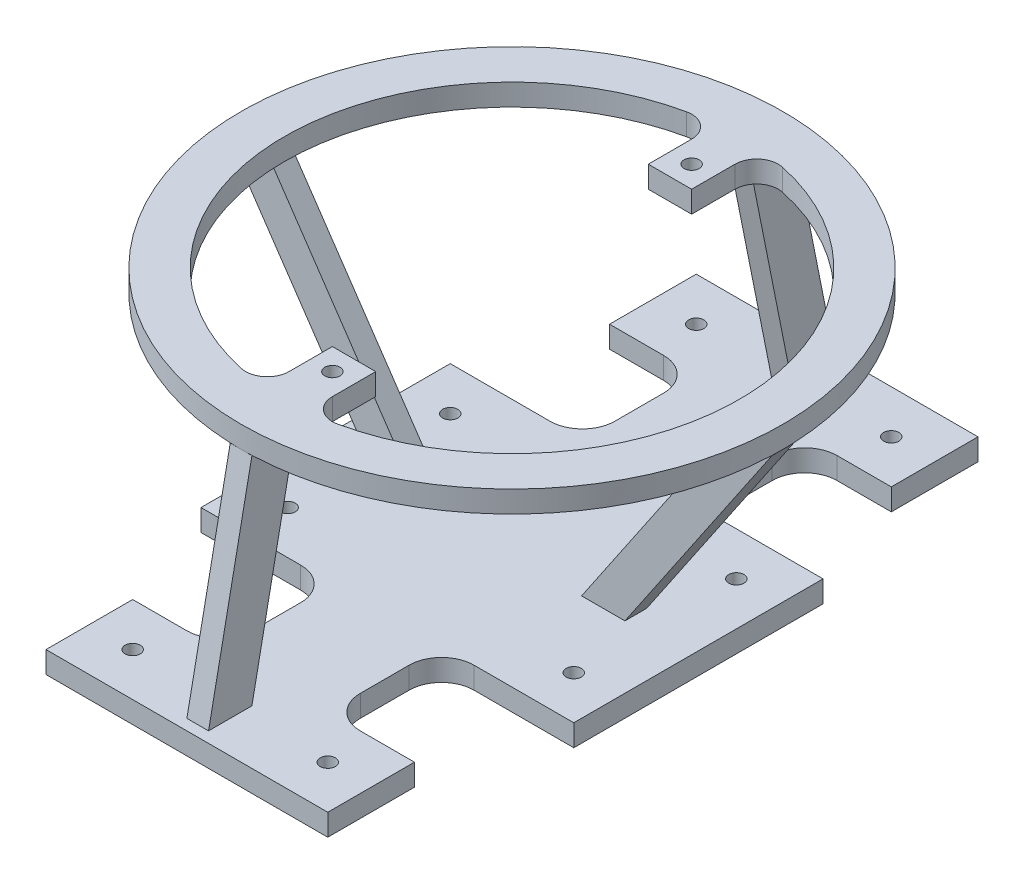
from build123d import *

# Parameters (mm, degrees)
AUFSATZ_LINEAR_AUSTRAGEN1_DEPTH    = 10
SKIZZE6_R                          = 125
AUFSATZ_LINEAR_AUSTRAGEN2_DEPTH    = 10
AUFSATZ_LINEAR_AUSTRAGEN3_DEPTH    = 5
SKIZZE8_W                          = 50
SKIZZE8_H                          = 20
SCHNITT_LINEAR_AUSTRAGEN1_DEPTH    = 10
AUFSATZ_LINEAR_AUSTRAGEN4_DEPTH    = 10
SKIZZE14_W                         = 24
SKIZZE14_H                         = 115
SCHNITT_LINEAR_AUSTRAGEN2_DEPTH    = 10
SKIZZE15_W                         = 24
SKIZZE15_H                         = 115
SCHNITT_LINEAR_AUSTRAGEN3_DEPTH    = 10
AUFSATZ_LINEAR_AUSTRAGEN8_DEPTH    = 5
KERNLOCH_F_R_M8X1_0_GEWINDE2_D     = 7
KERNLOCH_F_R_M8X1_0_GEWINDE2_DEPTH = 20
KERNLOCH_F_R_M8X1_0_GEWINDE2_TIP   = 2.103012167
KERNLOCH_F_R_M8X1_0_GEWINDE3_D     = 7
KERNLOCH_F_R_M8X1_0_GEWINDE3_DEPTH = 20
KERNLOCH_F_R_M8X1_0_GEWINDE3_TIP   = 2.103012167


with BuildPart() as part:
    # Skizze1 → Aufsatz-Linear austragen1 (new body)
    with BuildSketch(Plane(origin=(0, 0, 0), x_dir=(1, 0, 0), z_dir=(0, 1, 0))):
        with BuildLine():
            Line((75.838298065, 35.851170731), (145.838298065, 35.851170731))
            Line((145.838298065, 35.851170731), (145.838298065, -79.148829269))
            Line((145.838298065, -79.148829269), (75.838298065, -79.148829269))
            ThreePointArc((75.838298065, -79.148829269), (65.231696347, -83.542227551), (60.838298065, -94.148829269))
            Line((60.838298065, -94.148829269), (60.838298065, -191.648829269))
            Line((60.838298065, -191.648829269), (10.838298065, -191.648829269))
            Line((10.838298065, -191.648829269), (10.838298065, -94.148829269))
            ThreePointArc((10.838298065, -94.148829269), (6.444899783, -83.542227551), (-4.161701935, -79.148829269))
            Line((-4.161701935, -79.148829269), (-74.161701935, -79.148829269))
            Line((-74.161701935, -79.148829269), (-74.161701935, 35.851170731))
            Line((-74.161701935, 35.851170731), (-4.161701935, 35.851170731))
            ThreePointArc((-4.161701935, 35.851170731), (6.444899783, 40.244569014), (10.838298065, 50.851170731))
            Line((10.838298065, 50.851170731), (10.838298065, 148.351170731))
            Line((10.838298065, 148.351170731), (60.838298065, 148.351170731))
            Line((60.838298065, 148.351170731), (60.838298065, 50.851170731))
            ThreePointArc((60.838298065, 50.851170731), (65.231696347, 40.244569014), (75.838298065, 35.851170731))
        make_face()
    extrude(amount=AUFSATZ_LINEAR_AUSTRAGEN1_DEPTH)



with BuildPart() as body_2:
    # Skizze6 → Aufsatz-Linear austragen2 (new body)
    with BuildSketch(Plane(origin=(0, 120, 0), x_dir=(1, 0, 0), z_dir=(0, 1, 0))):
        with Locations(Location((35.838298065, -21.648829269, 0), (0, 0, 270))):  # turned: the seam where the file's is
            Circle(SKIZZE6_R)
        with BuildLine():
            Line((25.838298065, 71.222048837), (25.838298065, 51.222048837))
            Line((25.838298065, 51.222048837), (45.838298065, 51.222048837))
            Line((45.838298065, 51.222048837), (45.838298065, 71.222048837))
            ThreePointArc((45.838298065, 71.222048837), (49.55548944, 79.001914889), (57.943561223, 80.997930742))
            ThreePointArc((57.943561223, 80.997930742), (140.838298065, -21.648829269), (57.943561223, -124.295589279))
            ThreePointArc((57.943561223, -124.295589279), (49.55548944, -122.299573426), (45.838298065, -114.519707374))
            Line((45.838298065, -114.519707374), (45.838298065, -94.519707374))
            Line((45.838298065, -94.519707374), (25.838298065, -94.519707374))
            Line((25.838298065, -94.519707374), (25.838298065, -114.519707374))
            ThreePointArc((25.838298065, -114.519707374), (22.121106689, -122.299573426), (13.733034907, -124.295589279))
            ThreePointArc((13.733034907, -124.295589279), (-69.161701935, -21.648829269), (13.733034907, 80.997930742))
            ThreePointArc((13.733034907, 80.997930742), (22.121106689, 79.001914889), (25.838298065, 71.222048837))
        make_face(mode=Mode.SUBTRACT)
    extrude(amount=-AUFSATZ_LINEAR_AUSTRAGEN2_DEPTH)


with BuildPart() as part_1:
    add(part.part)

    add(body_2.part)  # Aufsatz-Linear austragen3 merges body 2
    # Skizze7 → Aufsatz-Linear austragen3 (add, symmetric)
    with BuildSketch(Plane(origin=(35.838298065, 0, 0), x_dir=(0, 0, -1), z_dir=(1, 0, 0))):
        Polygon((-146.648829269, 110), (-126.648829269, 110), (-146.648829269, 10), (-166.648829269, 10), align=None)
    aufsatz_linear_austragen3 = extrude(amount=AUFSATZ_LINEAR_AUSTRAGEN3_DEPTH, both=True)

    # Spiegeln1: Aufsatz-Linear austragen3 across plane
    add(aufsatz_linear_austragen3.mirror(Plane.XY.offset(21.648829269)))

    # Skizze8 → Schnitt-Linear austragen1 (cut)
    with BuildSketch(Plane(origin=(0, 10, 0), x_dir=(1, 0, 0), z_dir=(0, 1, 0))):
        with Locations((35.838298065, 138.351170731)):
            Rectangle(SKIZZE8_W, SKIZZE8_H)
        with Locations((35.838298065, -181.648829269)):
            Rectangle(SKIZZE8_W, SKIZZE8_H)
    extrude(amount=-SCHNITT_LINEAR_AUSTRAGEN1_DEPTH, mode=Mode.SUBTRACT)

    # Skizze9 → Aufsatz-Linear austragen4 (add)
    with BuildSketch(Plane(origin=(0, 10, 0), x_dir=(1, 0, 0), z_dir=(0, 1, 0))):
        with BuildLine():
            Line((60.838298065, -131.648829269), (60.838298065, -171.648829269))
            Line((60.838298065, -171.648829269), (100.838298065, -171.648829269))
            Line((100.838298065, -171.648829269), (100.838298065, -131.648829269))
            Line((100.838298065, -131.648829269), (75.838298065, -131.648829269))
            ThreePointArc((75.838298065, -131.648829269), (65.231696347, -127.255430986), (60.838298065, -116.648829269))
            Line((60.838298065, -116.648829269), (60.838298065, -131.648829269))
        make_face()
        with BuildLine():
            Line((-29.161701935, -171.648829269), (10.838298065, -171.648829269))
            Line((10.838298065, -171.648829269), (10.838298065, -131.648829269))
            Line((10.838298065, -131.648829269), (10.838298065, -116.648829269))
            ThreePointArc((10.838298065, -116.648829269), (6.444899783, -127.255430986), (-4.161701935, -131.648829269))
            Line((-4.161701935, -131.648829269), (-29.161701935, -131.648829269))
            Line((-29.161701935, -131.648829269), (-29.161701935, -171.648829269))
        make_face()
        with BuildLine():
            Line((100.838298065, 128.351170731), (60.838298065, 128.351170731))
            Line((60.838298065, 128.351170731), (60.838298065, 88.351170731))
            Line((60.838298065, 88.351170731), (60.838298065, 73.351170731))
            ThreePointArc((60.838298065, 73.351170731), (65.231696347, 83.957772449), (75.838298065, 88.351170731))
            Line((75.838298065, 88.351170731), (100.838298065, 88.351170731))
            Line((100.838298065, 88.351170731), (100.838298065, 128.351170731))
        make_face()
        with BuildLine():
            Line((10.838298065, 88.351170731), (10.838298065, 128.351170731))
            Line((10.838298065, 128.351170731), (-29.161701935, 128.351170731))
            Line((-29.161701935, 128.351170731), (-29.161701935, 88.351170731))
            Line((-29.161701935, 88.351170731), (-4.161701935, 88.351170731))
            ThreePointArc((-4.161701935, 88.351170731), (6.444899783, 83.957772449), (10.838298065, 73.351170731))
            Line((10.838298065, 73.351170731), (10.838298065, 88.351170731))
        make_face()
    extrude(amount=-AUFSATZ_LINEAR_AUSTRAGEN4_DEPTH)

    # Skizze14 → Schnitt-Linear austragen2 (cut)
    with BuildSketch(Plane(origin=(0, 10, 0), x_dir=(1, 0, 0), z_dir=(0, 1, 0))):
        with Locations((133.838298065, -21.648829269)):
            Rectangle(SKIZZE14_W, SKIZZE14_H)
    extrude(amount=-SCHNITT_LINEAR_AUSTRAGEN2_DEPTH, mode=Mode.SUBTRACT)

    # Skizze15 → Schnitt-Linear austragen3 (cut)
    with BuildSketch(Plane(origin=(0, 10, 0), x_dir=(1, 0, 0), z_dir=(0, 1, 0))):
        with Locations((-62.161701935, -21.648829269)):
            Rectangle(SKIZZE15_W, SKIZZE15_H)
    extrude(amount=-SCHNITT_LINEAR_AUSTRAGEN3_DEPTH, mode=Mode.SUBTRACT)

    # Skizze16 → Aufsatz-Linear austragen8 (add, symmetric)
    with BuildSketch(Plane.XY.offset(21.648829269)):
        Polygon((-89.161701935, 110), (-69.161701935, 110), (0, 8.135310029), (-20, 8.135310029), align=None)
    aufsatz_linear_austragen8 = extrude(amount=AUFSATZ_LINEAR_AUSTRAGEN8_DEPTH, both=True)

    # Spiegeln5: Aufsatz-Linear austragen8 across plane
    add(aufsatz_linear_austragen8.mirror(Plane(origin=(35.838298065, 0, 0), x_dir=(0, 0, 1), z_dir=(1, 0, 0))))

    # Kernloch für M8x1.0 Gewinde2
    with Locations(Plane(origin=(35.838298065, 110, -61.222048837), x_dir=(0, 0, -1), z_dir=(0, -1, 0))):
        with Locations((0, 0), (-165.741756211, 0)):
            Hole(KERNLOCH_F_R_M8X1_0_GEWINDE2_D / 2, depth=KERNLOCH_F_R_M8X1_0_GEWINDE2_DEPTH)
            with Locations((0, 0, -(KERNLOCH_F_R_M8X1_0_GEWINDE2_DEPTH + KERNLOCH_F_R_M8X1_0_GEWINDE2_TIP / 2))):  # 118° drill point
                Cone(0, KERNLOCH_F_R_M8X1_0_GEWINDE2_D / 2, KERNLOCH_F_R_M8X1_0_GEWINDE2_TIP, mode=Mode.SUBTRACT)

    # Kernloch für M8x1.0 Gewinde3
    with Locations(Plane(origin=(101.838298065, 10, -15.851170731), x_dir=(0, 0, 1), z_dir=(0, 1, 0))):
        with Locations((0, 0), (75, 0), (0, -132), (-92.5, -111), (75, -132), (167.5, -111), (167.5, -21), (-92.5, -21)):
            Hole(KERNLOCH_F_R_M8X1_0_GEWINDE3_D / 2, depth=KERNLOCH_F_R_M8X1_0_GEWINDE3_DEPTH)
            with Locations((0, 0, -(KERNLOCH_F_R_M8X1_0_GEWINDE3_DEPTH + KERNLOCH_F_R_M8X1_0_GEWINDE3_TIP / 2))):  # 118° drill point
                Cone(0, KERNLOCH_F_R_M8X1_0_GEWINDE3_D / 2, KERNLOCH_F_R_M8X1_0_GEWINDE3_TIP, mode=Mode.SUBTRACT)


solid = part_1.part
